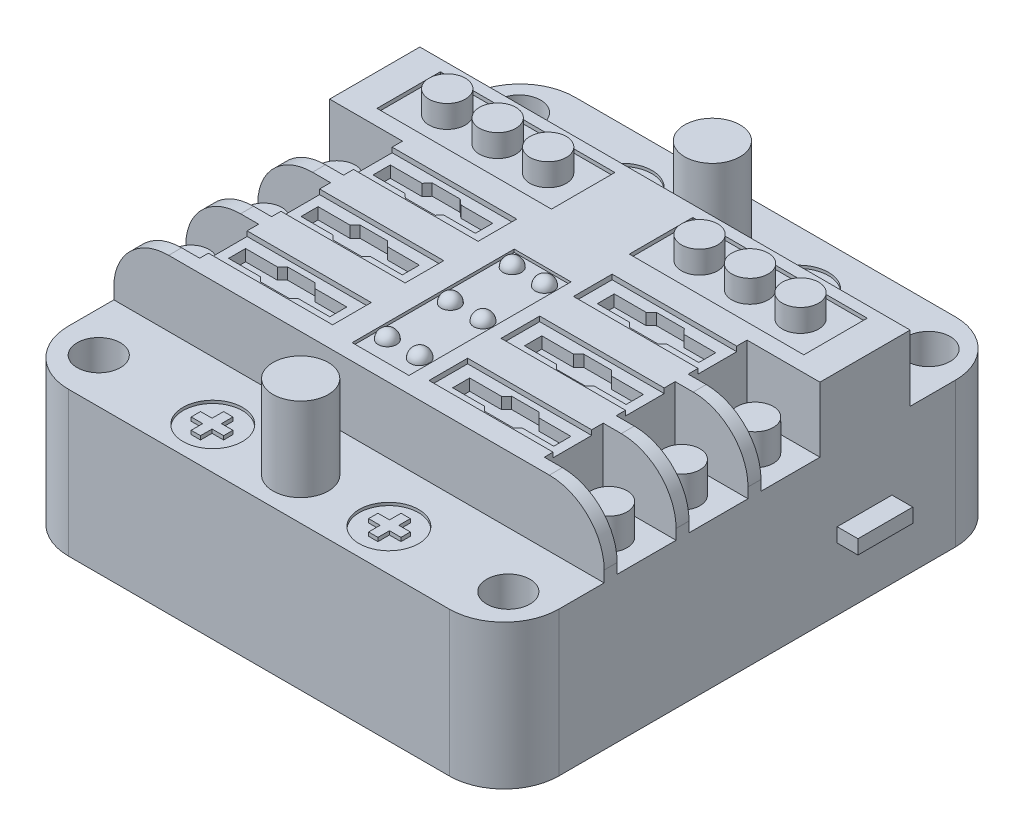
from build123d import *

# Parameters (mm, degrees)
SKETCH1_W            = 85
SKETCH1_H            = 87.75
BOSS_EXTRUDE1_DEPTH  = 36.5
SKETCH2_W            = 85
SKETCH2_H            = 17.35
CUT_EXTRUDE1_DEPTH   = 11.44
SKETCH3_W            = 85
SKETCH3_H            = 17.35
CUT_EXTRUDE2_DEPTH   = 11.44
SKETCH5_R            = 4.8
BOSS_EXTRUDE2_DEPTH  = 14.5
SKETCH6_R            = 4.8
BOSS_EXTRUDE3_DEPTH  = 14.5
SKETCH7_R            = 3.75
CUT_EXTRUDE3_DEPTH   = 26.5
SKETCH8_R            = 3.75
CUT_EXTRUDE4_DEPTH   = 26.5
SKETCH9_W            = 12.63
SKETCH9_H            = 10.22
CUT_EXTRUDE5_DEPTH   = 11.27
FILLET1_R            = 9.5
SKETCH10_W           = 12.63
SKETCH10_H           = 10.22
CUT_EXTRUDE6_DEPTH   = 11.27
FILLET2_R            = 9.5
SKETCH12_R           = 3.15
BOSS_EXTRUDE4_DEPTH  = 5.4
SKETCH13_W           = 30.25
SKETCH13_H           = 11
CUT_EXTRUDE7_DEPTH   = 0.65
SKETCH14_R           = 3.15
BOSS_EXTRUDE5_DEPTH  = 3.9
SKETCH15_R           = 5.15
CUT_EXTRUDE8_DEPTH   = 0.5
SKETCH16_W           = 6.33
SKETCH16_H           = 2
BOSS_EXTRUDE6_DEPTH  = 0.65
SKETCH18_R           = 5.15
CUT_EXTRUDE9_DEPTH   = 0.5
BOSS_EXTRUDE7_DEPTH  = 0.65
CUT_EXTRUDE10_DEPTH  = 0.5
SKETCH27_W           = 21.6
SKETCH27_H           = 6.7
CUT_EXTRUDE13_DEPTH  = 0.85
CUT_EXTRUDE14_DEPTH  = 2
FILLET3_R            = 9.5
SKETCH29_W           = 9.5
SKETCH29_H           = 2.45
BOSS_EXTRUDE9_DEPTH  = 3.6
SKETCH30_W           = 9.5
SKETCH30_H           = 2.45
BOSS_EXTRUDE10_DEPTH = 3.6


with BuildPart() as part:
    # Sketch1 → Boss-Extrude1 (new body)
    with BuildSketch(Plane(origin=(0, 0, 0), x_dir=(1, 0, 0), z_dir=(0, 1, 0))):
        Rectangle(SKETCH1_W, SKETCH1_H)
    extrude(amount=BOSS_EXTRUDE1_DEPTH)

    # Sketch2 → Cut-Extrude1 (cut)
    with BuildSketch(Plane(origin=(0, 36.5, 0), x_dir=(1, 0, 0), z_dir=(0, 1, 0))):
        with Locations((0, 35.2)):
            Rectangle(SKETCH2_W, SKETCH2_H)
    extrude(amount=-CUT_EXTRUDE1_DEPTH, mode=Mode.SUBTRACT)

    # Sketch3 → Cut-Extrude2 (cut)
    with BuildSketch(Plane(origin=(0, 36.5, 0), x_dir=(1, 0, 0), z_dir=(0, 1, 0))):
        with Locations((0, -35.2)):
            Rectangle(SKETCH3_W, SKETCH3_H)
    extrude(amount=-CUT_EXTRUDE2_DEPTH, mode=Mode.SUBTRACT)

    # Sketch5 → Boss-Extrude2 (add)
    with BuildSketch(Plane(origin=(0, 25.06, 0), x_dir=(1, 0, 0), z_dir=(0, 1, 0))):
        with Locations((0, -36.63403506)):
            Circle(SKETCH5_R)
    extrude(amount=BOSS_EXTRUDE2_DEPTH)

    # Sketch6 → Boss-Extrude3 (add)
    with BuildSketch(Plane(origin=(0, 25.06, 0), x_dir=(1, 0, 0), z_dir=(0, 1, 0))):
        with Locations((0, 34.736326037)):
            Circle(SKETCH6_R)
    extrude(amount=BOSS_EXTRUDE3_DEPTH)

    # Sketch7 → Cut-Extrude3 (cut)
    with BuildSketch(Plane(origin=(0, 25.06, 0), x_dir=(1, 0, 0), z_dir=(0, 1, 0))):
        with Locations((-35.5, 36.716544148)):
            Circle(SKETCH7_R)
        with Locations((35.5, 36.716544148)):
            Circle(SKETCH7_R)
    extrude(amount=-CUT_EXTRUDE3_DEPTH, mode=Mode.SUBTRACT)

    # Sketch8 → Cut-Extrude4 (cut)
    with BuildSketch(Plane(origin=(0, 25.06, 0), x_dir=(1, 0, 0), z_dir=(0, 1, 0))):
        with Locations((-35.5, -36.138980532)):
            Circle(SKETCH8_R)
        with Locations((35.5, -36.138980532)):
            Circle(SKETCH8_R)
    extrude(amount=-CUT_EXTRUDE4_DEPTH, mode=Mode.SUBTRACT)

    # Sketch9 → Cut-Extrude5 (cut)
    with BuildSketch(Plane(origin=(0, 36.5, 0), x_dir=(1, 0, 0), z_dir=(0, 1, 0))):
        with Locations((36.185, -19.165)):
            Rectangle(SKETCH9_W, SKETCH9_H)
        with Locations((36.185, -6.695)):
            Rectangle(SKETCH9_W, SKETCH9_H)
        with Locations((36.185, 5.775)):
            Rectangle(SKETCH9_W, SKETCH9_H)
    extrude(amount=-CUT_EXTRUDE5_DEPTH, mode=Mode.SUBTRACT)

    # Fillet1
    fillet1_edges = [part.edges().sort_by_distance(p)[0] for p in [
        (42.5, 36.5, 25.4),
        (42.5, 36.5, 12.93),
        (42.5, 36.5, 0.46),
    ]]
    fillet(fillet1_edges, radius=FILLET1_R)

    # Sketch10 → Cut-Extrude6 (cut)
    with BuildSketch(Plane(origin=(0, 36.5, 0), x_dir=(1, 0, 0), z_dir=(0, 1, 0))):
        with Locations((-36.185, -19.165)):
            Rectangle(SKETCH10_W, SKETCH10_H)
        with Locations((-36.185, -6.695)):
            Rectangle(SKETCH10_W, SKETCH10_H)
        with Locations((-36.185, 5.775)):
            Rectangle(SKETCH10_W, SKETCH10_H)
    extrude(amount=-CUT_EXTRUDE6_DEPTH, mode=Mode.SUBTRACT)

    # Fillet2
    fillet2_edges = [part.edges().sort_by_distance(p)[0] for p in [
        (-42.5, 36.5, 0.46),
        (-42.5, 36.5, 12.93),
        (-42.5, 36.5, 25.4),
    ]]
    fillet(fillet2_edges, radius=FILLET2_R)

    # Sketch12 → Boss-Extrude4 (add)
    with BuildSketch(Plane(origin=(0, 25.23, 0), x_dir=(1, 0, 0), z_dir=(0, 1, 0))):
        with Locations((-36.247555492, -6.797719079)):
            Circle(SKETCH12_R)
        with Locations((-36.247555492, 5.910055407)):
            Circle(SKETCH12_R)
        with Locations((-36.247555492, -19.421702984)):
            Circle(SKETCH12_R)
        with Locations((36.23312972, -19.421702984)):
            Circle(SKETCH12_R)
        with Locations((36.23312972, -6.797719079)):
            Circle(SKETCH12_R)
        with Locations((36.23312972, 5.910055407)):
            Circle(SKETCH12_R)
    extrude(amount=BOSS_EXTRUDE4_DEPTH)

    # Sketch13 → Cut-Extrude7 (cut)
    with BuildSketch(Plane(origin=(0, 36.5, 0), x_dir=(1, 0, 0), z_dir=(0, 1, 0))):
        with Locations((-21.875, 19.087708216)):
            Rectangle(SKETCH13_W, SKETCH13_H)
        with Locations((21.875, 19.087708216)):
            Rectangle(SKETCH13_W, SKETCH13_H)
    extrude(amount=-CUT_EXTRUDE7_DEPTH, mode=Mode.SUBTRACT)

    # Sketch14 → Boss-Extrude5 (add)
    with BuildSketch(Plane(origin=(0, 35.85, 0), x_dir=(1, 0, 0), z_dir=(0, 1, 0))):
        with Locations((-30.625, 19.389635674)):
            Circle(SKETCH14_R)
        with Locations((-21.875, 19.389635674)):
            Circle(SKETCH14_R)
        with Locations((-13.125, 19.389635674)):
            Circle(SKETCH14_R)
        with Locations((13.125, 19.389635674)):
            Circle(SKETCH14_R)
        with Locations((21.875, 19.389635674)):
            Circle(SKETCH14_R)
        with Locations((30.625, 19.389635674)):
            Circle(SKETCH14_R)
    extrude(amount=BOSS_EXTRUDE5_DEPTH)

    # Sketch15 → Cut-Extrude8 (cut)
    with BuildSketch(Plane(origin=(0, 25.06, 0), x_dir=(1, 0, 0), z_dir=(0, 1, 0))):
        with Locations((-15.3, 34.406289685)):
            Circle(SKETCH15_R)
        with Locations((15.3, 34.406289685)):
            Circle(SKETCH15_R)
    extrude(amount=-CUT_EXTRUDE8_DEPTH, mode=Mode.SUBTRACT)

    # Sketch16 → Boss-Extrude6 (add)
    with BuildSketch(Plane(origin=(0, 24.56, 0), x_dir=(1, 0, 0), z_dir=(0, 1, 0))):
        with Locations((-15.544936327, 34.418454167)):
            Rectangle(SKETCH16_W, SKETCH16_H)
        with Locations((15.298757674, 34.418454167)):
            Rectangle(SKETCH16_W, SKETCH16_H)
    extrude(amount=BOSS_EXTRUDE6_DEPTH)

    # Sketch18 → Cut-Extrude9 (cut)
    with BuildSketch(Plane(origin=(0, 25.06, 0), x_dir=(1, 0, 0), z_dir=(0, 1, 0))):
        with Locations((-15.222926731, -36.655004663)):
            Circle(SKETCH18_R)
        with Locations((15.377073269, -36.716544148)):
            Circle(SKETCH18_R)
    extrude(amount=-CUT_EXTRUDE9_DEPTH, mode=Mode.SUBTRACT)

    # Sketch19 → Boss-Extrude7 (add)
    with BuildSketch(Plane(origin=(0, 24.56, 0), x_dir=(1, 0, 0), z_dir=(0, 1, 0))):
        Polygon((-16.066136613, -35.930877042), (-16.066136613, -33.930877042), (-14.446136613, -33.930877042), (-14.446136613, -35.930877042), (-12.446136613, -35.930877042), (-12.446136613, -37.550877042), (-14.446136613, -37.550877042), (-14.446136613, -39.550877042), (-16.066136613, -39.550877042), (-16.066136613, -37.550877042), (-18.066136613, -37.550877042), (-18.066136613, -35.930877042), align=None)
        Polygon((14.577407733, -35.818305265), (14.577407733, -33.818305265), (16.197407733, -33.818305265), (16.197407733, -35.818305265), (18.197407733, -35.818305265), (18.197407733, -37.438305265), (16.197407733, -37.438305265), (16.197407733, -39.438305265), (14.577407733, -39.438305265), (14.577407733, -37.438305265), (12.577407733, -37.438305265), (12.577407733, -35.818305265), align=None)
    extrude(amount=BOSS_EXTRUDE7_DEPTH)

    # Sketch20 → Cut-Extrude10 (cut)
    with BuildSketch(Plane(origin=(0, 36.5, 0), x_dir=(1, 0, 0), z_dir=(0, 1, 0))):
        Polygon((5.87, -23.735), (5.87, -12.508485939), (5.87, 4.365), (-3.98, 4.365), (-3.98, -23.735), align=None)
    extrude(amount=-CUT_EXTRUDE10_DEPTH, mode=Mode.SUBTRACT)

    # Sketch21 → Revolve2 (revolve)
    with BuildSketch(Plane(origin=(0, 36, 0), x_dir=(1, 0, 0), z_dir=(0, 1, 0))):
        with BuildLine():
            Line((-3.538963567, 1.980218111), (-0.338963567, 1.980218111))
            ThreePointArc((-0.338963567, 1.980218111), (-1.938963567, 3.580218111), (-3.538963567, 1.980218111))
        make_face()
    revolve(axis=Axis((-3.538963567, 36, -1.980218111), (1, 0, 0)))

    # Sketch22 → Revolve3 (revolve)
    with BuildSketch(Plane(origin=(0, 36, 0), x_dir=(1, 0, 0), z_dir=(0, 1, 0))):
        with BuildLine():
            Line((2.063672439, 1.97740199), (5.263672439, 1.97740199))
            ThreePointArc((5.263672439, 1.97740199), (3.663672439, 3.57740199), (2.063672439, 1.97740199))
        make_face()
    revolve(axis=Axis((2.063672439, 36, -1.97740199), (1, 0, 0)))

    # Sketch24 → Revolve4 (revolve)
    with BuildSketch(Plane(origin=(0, 36, 0), x_dir=(1, 0, 0), z_dir=(0, 1, 0))):
        with BuildLine():
            Line((-3.538157978, -8.749301696), (-0.338157978, -8.749301696))
            ThreePointArc((-0.338157978, -8.749301696), (-1.938157978, -7.149301696), (-3.538157978, -8.749301696))
        make_face()
    revolve(axis=Axis((-3.538157978, 36, 8.749301696), (1, 0, 0)))

    # Sketch25 → Revolve5 (revolve)
    with BuildSketch(Plane(origin=(0, 36, 0), x_dir=(1, 0, 0), z_dir=(0, 1, 0))):
        with BuildLine():
            Line((2.075477833, -8.706074), (5.275477833, -8.706074))
            ThreePointArc((5.275477833, -8.706074), (3.675477833, -7.106074), (2.075477833, -8.706074))
        make_face()
    revolve(axis=Axis((2.075477833, 36, 8.706074), (1, 0, 0)))

    # Sketch26 → Revolve6 (revolve)
    with BuildSketch(Plane(origin=(0, 36, 0), x_dir=(1, 0, 0), z_dir=(0, 1, 0))):
        with BuildLine():
            Line((-3.528694356, -19.680752267), (-0.328694356, -19.680752267))
            ThreePointArc((-0.328694356, -19.680752267), (-1.928694356, -18.080752267), (-3.528694356, -19.680752267))
        make_face()
        with BuildLine():
            Line((2.081617277, -19.634533638), (5.281617277, -19.634533638))
            ThreePointArc((5.281617277, -19.634533638), (3.681617277, -18.034533638), (2.081617277, -19.634533638))
        make_face()
    revolve(axis=Axis((-3.528694356, 36, 19.680752267), (1, 0, 0)))

    # Sketch27 → Cut-Extrude13 (cut)
    with BuildSketch(Plane(origin=(0, 36.5, 0), x_dir=(1, 0, 0), z_dir=(0, 1, 0))):
        with Locations((19.07, 5.737708216)):
            Rectangle(SKETCH27_W, SKETCH27_H)
        with Locations((19.081709964, -6.832291784)):
            Rectangle(SKETCH27_W, SKETCH27_H)
        with Locations((19.162233612, -19.402291784)):
            Rectangle(SKETCH27_W, SKETCH27_H)
        with Locations((-19.146222333, -19.402291784)):
            Rectangle(SKETCH27_W, SKETCH27_H)
        with Locations((-19.146222333, -6.832291784)):
            Rectangle(SKETCH27_W, SKETCH27_H)
        with Locations((-19.07080751, 5.737708216)):
            Rectangle(SKETCH27_W, SKETCH27_H)
    extrude(amount=-CUT_EXTRUDE13_DEPTH, mode=Mode.SUBTRACT)

    # Sketch28 → Cut-Extrude14 (cut)
    with BuildSketch(Plane(origin=(0, 35.65, 0), x_dir=(1, 0, 0), z_dir=(0, 1, 0))):
        Polygon((-28.2, 7.102156883), (-28.2, 4.102156883), (-22.69, 4.102156883), (-21.925911516, 3.437708216), (-16.753002722, 3.437708216), (-16.076562918, 4.215586011), (-10.566562918, 4.215586011), (-10.566562918, 7.215586011), (-16.076562918, 7.215586011), (-17.021969449, 8.037708216), (-21.876447841, 8.037708216), (-22.69, 7.102156883), align=None)
        Polygon((-28.2, -5.4182033), (-28.2, -8.3682033), (-22.69, -8.3682033), (-21.925911516, -9.132291784), (-16.900146417, -9.132291784), (-16.136057933, -8.3682033), (-10.646222333, -8.3682033), (-10.646222333, -5.4182033), (-16.136057933, -5.4182033), (-17.021969449, -4.532291784), (-21.804088484, -4.532291784), (-22.69, -5.4182033), align=None)
        Polygon((-28.2, -17.9882033), (-28.2, -20.9382033), (-22.69, -20.9382033), (-21.925911516, -21.702291784), (-16.900146417, -21.702291784), (-16.136057933, -20.9382033), (-10.646222333, -20.9382033), (-10.646222333, -17.9882033), (-16.136057933, -17.9882033), (-17.021969449, -17.102291784), (-21.804088484, -17.102291784), (-22.69, -17.9882033), align=None)
        Polygon((10.57, 7.1517967), (10.57, 4.224859878), (16.159839262, 4.224859878), (16.900146417, 3.437708216), (21.925911516, 3.437708216), (22.713063178, 4.178015371), (28.2, 4.178015371), (28.2, 7.125056426), (22.69, 7.125056426), (21.831661408, 8.037708216), (17.021969449, 8.037708216), (16.08, 7.1517967), align=None)
        Polygon((10.583344678, -5.4182033), (10.583344678, -8.4182033), (16.136057933, -8.4182033), (16.900146417, -9.182291784), (21.925911516, -9.182291784), (22.69, -8.4182033), (28.2, -8.4182033), (28.2, -5.4182033), (22.69, -5.4182033), (21.804088484, -4.532291784), (16.979256194, -4.532291784), (16.093344678, -5.4182033), align=None)
        Polygon((10.662233612, -18.000177598), (10.662233612, -20.948672513), (16.161905917, -20.948672513), (16.936322096, -21.702291784), (21.962087195, -21.702291784), (22.69, -20.954291468), (28.2, -20.954291468), (28.2, -17.9882033), (22.69, -17.9882033), (21.779640834, -17.102291784), (17.046006747, -17.102291784), (16.172233612, -18.000177598), align=None)
    extrude(amount=-CUT_EXTRUDE14_DEPTH, mode=Mode.SUBTRACT)

    # Fillet3
    fillet3_edges = [part.edges().sort_by_distance(p)[0] for p in [
        (-42.5, 12.53, -43.875),
        (42.5, 12.53, -43.875),
        (42.5, 12.53, 43.875),
        (-42.5, 12.53, 43.875),
    ]]
    fillet(fillet3_edges, radius=FILLET3_R)

    # Sketch29 → Boss-Extrude9 (add)
    with BuildSketch(Plane.ZY.offset(42.5)):
        with Locations((-18.625, 12.075)):
            Rectangle(SKETCH29_W, SKETCH29_H)
    extrude(amount=BOSS_EXTRUDE9_DEPTH)

    # Sketch30 → Boss-Extrude10 (add)
    with BuildSketch(Plane(origin=(42.5, 0, 0), x_dir=(0, 0, -1), z_dir=(1, 0, 0))):
        with Locations((18.625, 12.075)):
            Rectangle(SKETCH30_W, SKETCH30_H)
    extrude(amount=BOSS_EXTRUDE10_DEPTH)


solid = part.part
